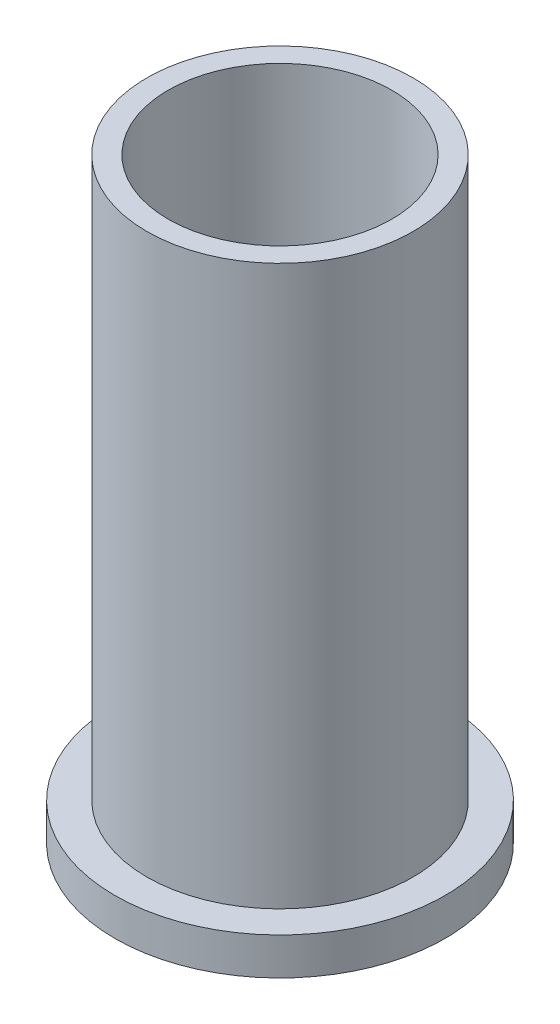
from build123d import *


with BuildPart() as part:
    # Sketch1 → Revolve1 (revolve)
    with BuildSketch(Plane.XY, mode=Mode.PRIVATE) as revolve1_sk:
        Polygon((21, 0), (25, 0), (25, -105), (31, -105), (31, -112), (21, -112), align=None)
    revolve(revolve1_sk.sketch.rotate(Axis((0, 0, 0), (0, -1, 0)), 90), axis=Axis((0, 0, 0), (0, -1, 0)))  # turned: the seam where the file's is


solid = part.part
